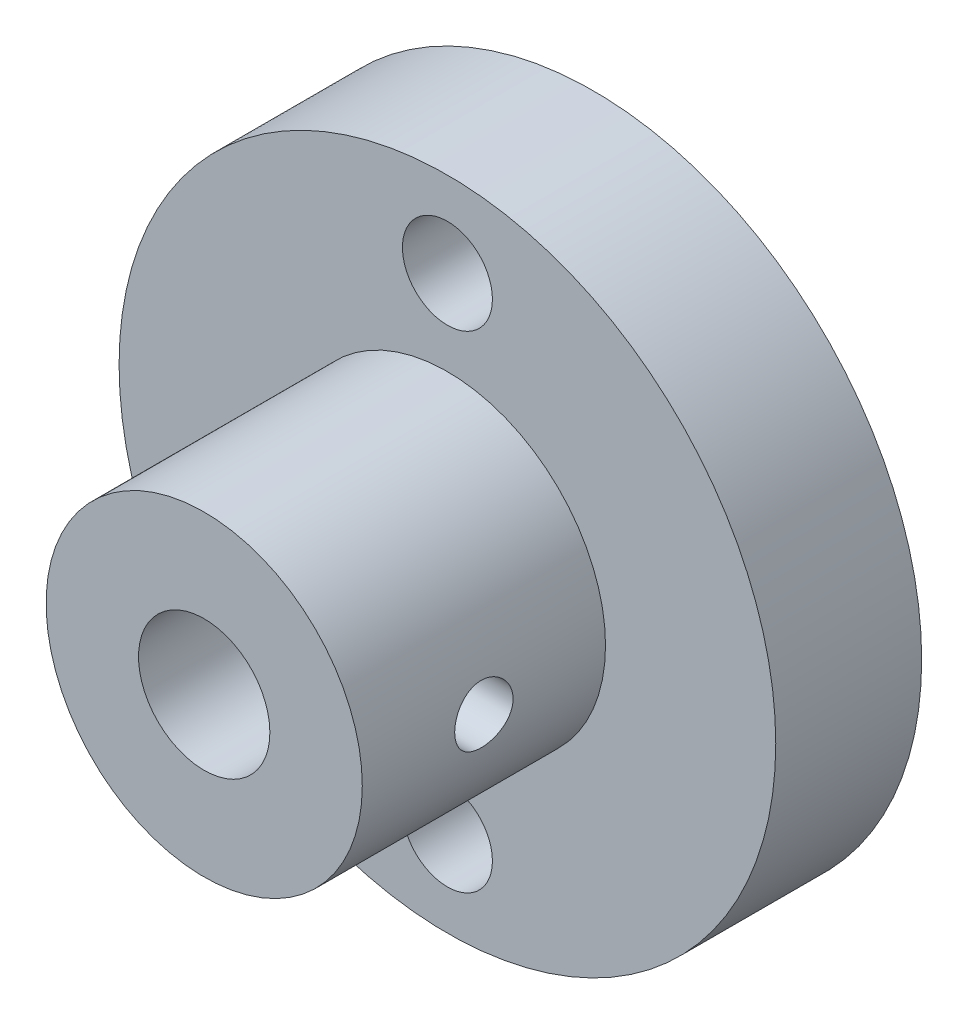
from build123d import *

# Parameters (mm, degrees)
SKETCH2_R               = 13.5
BOSS_EXTRUDE1_DEPTH     = 6
SKETCH3_R               = 6.5
SKETCH3_R_2             = 2.5
BOSS_EXTRUDE2_DEPTH     = 10
CUT_EXTRUDE1_DEPTH      = 25
CUT_EXTRUDE1_DEPTH_BACK = 25
SKETCH4_R               = 1.2
CUT_EXTRUDE3_DEPTH      = 50
CUT_EXTRUDE3_DEPTH_BACK = 20
SKETCH6_R               = 2.7
SKETCH5_R               = 1.85
CUT_EXTRUDE4_DEPTH      = 10


with BuildPart() as part:
    # Sketch2 → Boss-Extrude1 (new body)
    with BuildSketch(Plane.XY):
        Circle(SKETCH2_R)
    extrude(amount=BOSS_EXTRUDE1_DEPTH)

    # Sketch3 → Boss-Extrude2 (add)
    with BuildSketch(Plane.XY.offset(6)):
        Circle(SKETCH3_R)
        Circle(SKETCH3_R_2, mode=Mode.SUBTRACT)
    extrude(amount=BOSS_EXTRUDE2_DEPTH)

    # Sketch4 → Cut-Extrude1 (cut, two sides: drawn at the far end of the back side and taken through both)
    with BuildSketch(Plane(origin=(0, 0, 0), x_dir=(0, -1, 0), z_dir=(1, 0, 0)).offset(-CUT_EXTRUDE1_DEPTH_BACK)):
        with Locations((0, -11)):
            Circle(SKETCH4_R)
    extrude(amount=CUT_EXTRUDE1_DEPTH + CUT_EXTRUDE1_DEPTH_BACK, mode=Mode.SUBTRACT)

    # Sketch6 → Cut-Extrude3 (cut, two sides: drawn at the far end of the back side and taken through both)
    with BuildSketch(Plane.XY.offset(6).offset(-CUT_EXTRUDE3_DEPTH_BACK)):
        Circle(SKETCH6_R)
    extrude(amount=CUT_EXTRUDE3_DEPTH + CUT_EXTRUDE3_DEPTH_BACK, mode=Mode.SUBTRACT)

    # Sketch5 → Cut-Extrude4 (cut)
    with BuildSketch(Plane.XY.offset(6)):
        with Locations((0, 10)):
            Circle(SKETCH5_R)
    cut_extrude4 = extrude(amount=-CUT_EXTRUDE4_DEPTH, mode=Mode.SUBTRACT)

    # Mirror1: Cut-Extrude4 across plane
    add(cut_extrude4.mirror(Plane.ZX), mode=Mode.SUBTRACT)


solid = part.part
